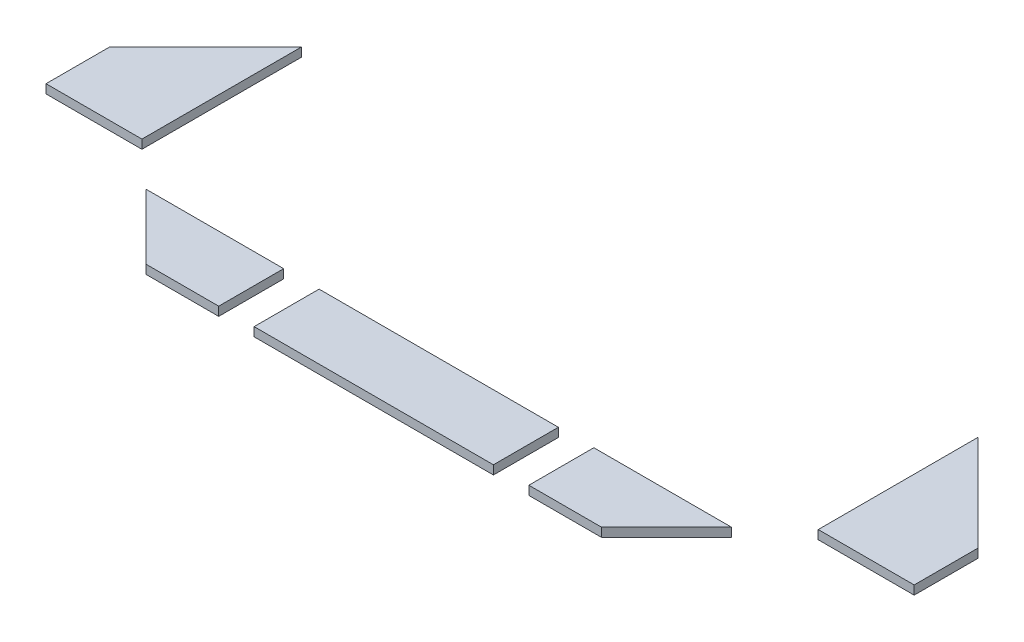
from build123d import *

# Parameters (mm, degrees)
BOSS_EXTRUDE1_DEPTH   = 1.5
SKETCH1_W             = 40.514718626
SKETCH1_H             = 11
BOSS_EXTRUDE1_2_DEPTH = 1.5
BOSS_EXTRUDE1_3_DEPTH = 1.5
BOSS_EXTRUDE1_4_DEPTH = 1.5
BOSS_EXTRUDE1_5_DEPTH = 1.5


with BuildPart() as part:
    # Sketch1 → Boss-Extrude1 (new body)
    with BuildSketch(Plane(origin=(0, 0, 0), x_dir=(1, 0, 0), z_dir=(0, 1, 0))):
        Polygon((-36.5, 18.5), (-36.5, 45.5), (-36.550252532, 45.5), (-52.742640687, 29.307611845), (-52.742640687, 18.5), align=None)
    extrude(amount=BOSS_EXTRUDE1_DEPTH)


with BuildPart() as body_2:
    # Sketch1 → Boss-Extrude1 2 (new body)
    with BuildSketch(Plane(origin=(0, 0, 0), x_dir=(1, 0, 0), z_dir=(0, 1, 0))):
        with Locations((20.757359313, 6)):
            Rectangle(SKETCH1_W, SKETCH1_H)
    extrude(amount=BOSS_EXTRUDE1_2_DEPTH)


with BuildPart() as body_3:
    # Sketch1 → Boss-Extrude1 3 (new body)
    with BuildSketch(Plane(origin=(0, 0, 0), x_dir=(1, 0, 0), z_dir=(0, 1, 0))):
        Polygon((-17.792893219, 0.5), (-28.792893219, 11.5), (-5.5, 11.5), (-5.5, 0.5), align=None)
    extrude(amount=BOSS_EXTRUDE1_3_DEPTH)


with BuildPart() as body_4:
    # Sketch1 → Boss-Extrude1 4 (new body)
    with BuildSketch(Plane(origin=(0, 0, 0), x_dir=(1, 0, 0), z_dir=(0, 1, 0))):
        Polygon((47.014718626, 0.5), (59.307611845, 0.5), (70.307611845, 11.5), (47.014718626, 11.5), align=None)
    extrude(amount=BOSS_EXTRUDE1_4_DEPTH)


with BuildPart() as body_5:
    # Sketch1 → Boss-Extrude1 5 (new body)
    with BuildSketch(Plane(origin=(0, 0, 0), x_dir=(1, 0, 0), z_dir=(0, 1, 0))):
        Polygon((94.257359313, 18.5), (78.014718626, 18.5), (78.014718626, 45.5), (78.064971157, 45.5), (94.257359313, 29.307611845), align=None)
    extrude(amount=BOSS_EXTRUDE1_5_DEPTH)


solid = Compound([part.part, body_2.part, body_3.part, body_4.part, body_5.part])
